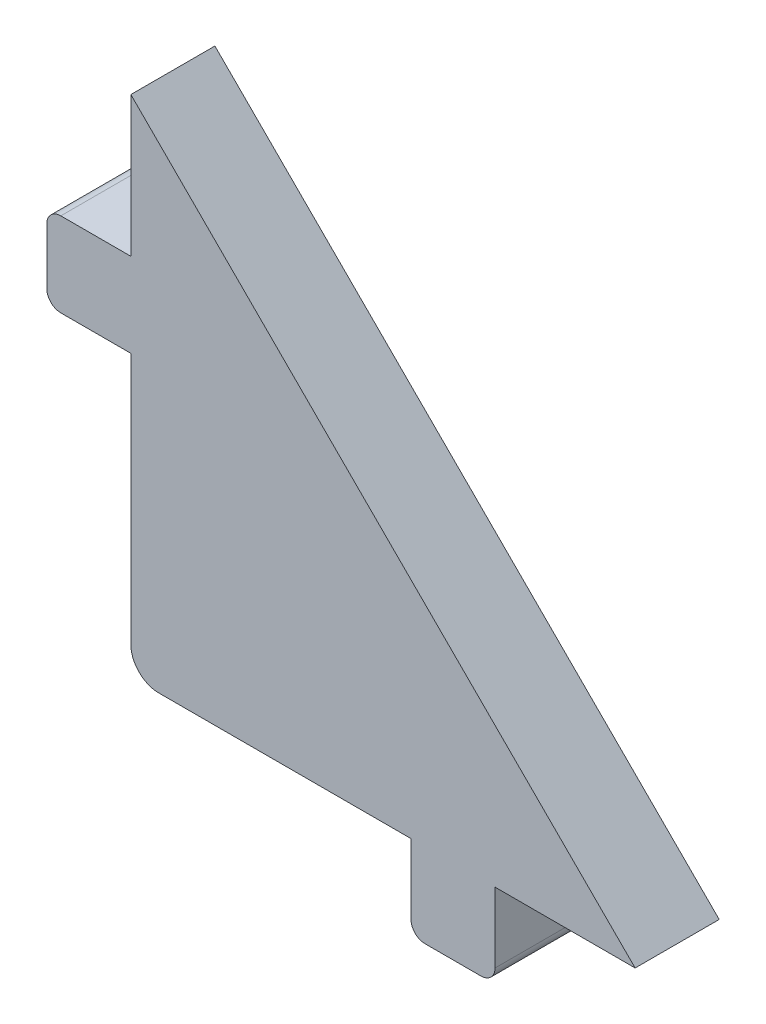
from build123d import *

# Parameters (mm, degrees)
EXTRUDE_1_DEPTH = 3
FILLET_1_R      = 0.5
FILLET_2_R      = 1


with BuildPart() as part:
    # Эскиз1 → Бобышка-Вытянуть1 (new body)
    with BuildSketch(Plane.XY):
        Polygon((3, 0), (0, 0), (0, 3), (8, 3), (16, -5), (16, -13), (13, -13), (13, -10), (3, -10), align=None)
        Polygon((3, 8), (3, 3), (8, 3), align=None)
        Polygon((21, -10), (16, -5), (16, -10), align=None)
    extrude(amount=EXTRUDE_1_DEPTH)

    # Скругление1
    fillet_1_edges = [part.edges().sort_by_distance(p)[0] for p in [
        (0, 0, 1.5),
        (0, 3, 1.5),
        (16, -13, 1.5),
        (13, -13, 1.5),
    ]]
    fillet(fillet_1_edges, radius=FILLET_1_R)

    # Скругление2
    fillet_2_edges = [part.edges().sort_by_distance(p)[0] for p in [
        (3, -10, 1.5),
    ]]
    fillet(fillet_2_edges, radius=FILLET_2_R)


solid = part.part
